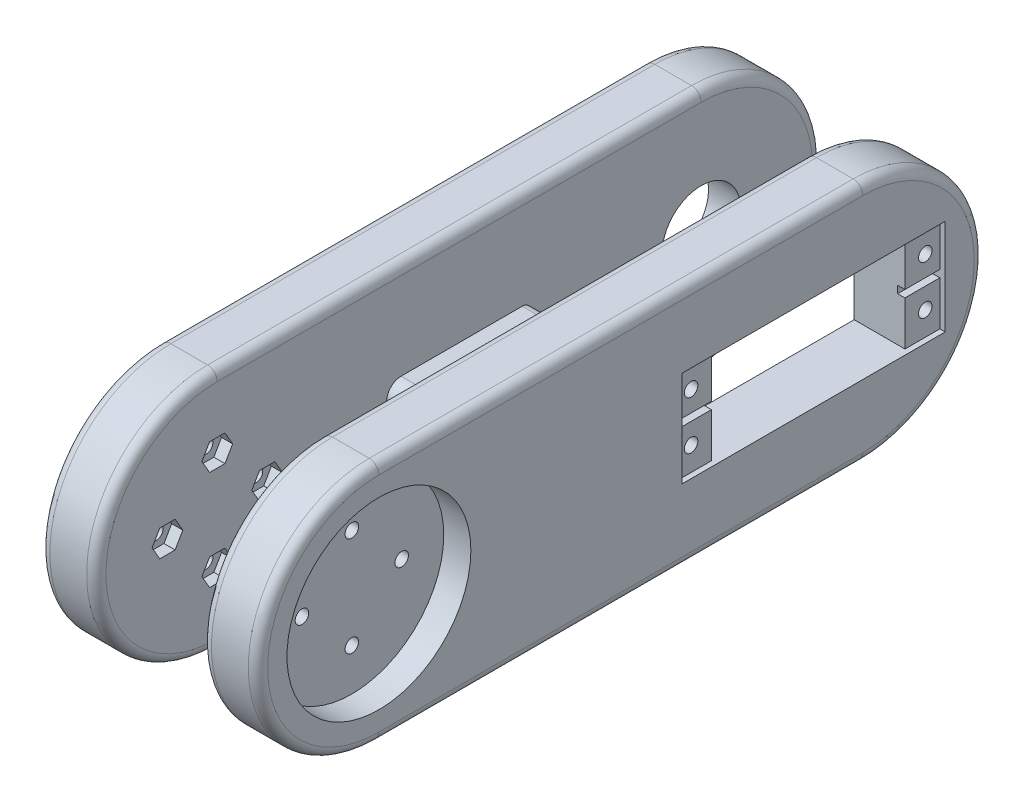
from build123d import *

# Parameters (mm, degrees)
SALIENTE_EXTRUIR1_DEPTH = 45
CROQUIS3_R              = 19
CORTAR_EXTRUIR1_DEPTH   = 5.6
CROQUIS4_R              = 19
CORTAR_EXTRUIR2_DEPTH   = 5.6
CROQUIS5_W              = 21.8
CROQUIS5_H              = 150
CORTAR_EXTRUIR3_DEPTH   = 55.6
CROQUIS6_W              = 30
CROQUIS6_H              = 10
SALIENTE_EXTRUIR2_DEPTH = 33.6
CROQUIS8_W              = 54.4
CROQUIS8_H              = 19.8
CORTAR_EXTRUIR4_DEPTH   = 1.1
CROQUIS9_W              = 40
CROQUIS9_H              = 19.8
CORTAR_EXTRUIR5_DEPTH   = 22
CROQUIS10_R             = 1.4
CORTAR_EXTRUIR6_DEPTH   = 9
CROQUIS11_W             = 54.4
CROQUIS11_H             = 1.5
CORTAR_EXTRUIR7_DEPTH   = 1.5
CROQUIS12_R             = 8.1
CORTAR_EXTRUIR8_DEPTH   = 17.5
CROQUIS13_R             = 17.5
CORTAR_EXTRUIR9_DEPTH   = 5
CROQUIS14_R             = 1.4
CORTAR_EXTRUIR10_DEPTH  = 5
CROQUIS15_R             = 1.4
CORTAR_EXTRUIR11_DEPTH  = 55
CORTAR_EXTRUIR12_DEPTH  = 2.3
CORTAR_EXTRUIR13_DEPTH  = 2.3
REDONDEO1_R             = 2
REDONDEO1_2_R           = 3


with BuildPart() as part:
    # Croquis2 → Saliente-Extruir1 (new body)
    with BuildSketch(Plane(origin=(0, 0, 0), x_dir=(0, 0, -1), z_dir=(1, 0, 0))):
        with BuildLine():
            Line((0, 25), (100, 25))
            ThreePointArc((100, 25), (125, -1.672e-06), (99.999996656, -25))
            Line((99.999996656, -25), (0, -25))
            ThreePointArc((0, -25), (-25, 0), (0, 25))
        make_face()
    extrude(amount=SALIENTE_EXTRUIR1_DEPTH)

    # Croquis3 → Cortar-Extruir1 (cut)
    with BuildSketch(Plane(origin=(45, 0, 0), x_dir=(0, 0, -1), z_dir=(1, 0, 0))):
        Circle(CROQUIS3_R)
    extrude(amount=-CORTAR_EXTRUIR1_DEPTH, mode=Mode.SUBTRACT)

    # Croquis4 → Cortar-Extruir2 (cut)
    with BuildSketch(Plane.ZY):
        with Locations(Location((0, 0, 0), (0, 0, 180))):  # turned: the seam where the file's is
            Circle(CROQUIS4_R)
    extrude(amount=-CORTAR_EXTRUIR2_DEPTH, mode=Mode.SUBTRACT)

    # Croquis5 → Cortar-Extruir3 (cut)
    with BuildSketch(Plane(origin=(0, 25, 0), x_dir=(1, 0, 0), z_dir=(0, 1, 0))):
        with Locations((22.5, 50)):
            Rectangle(CROQUIS5_W, CROQUIS5_H)
    extrude(amount=-CORTAR_EXTRUIR3_DEPTH, mode=Mode.SUBTRACT)

    # Croquis6 → Saliente-Extruir2 (add)
    with BuildSketch(Plane.ZY.offset(-5.6)):
        with Locations((-50, -1.672e-06)):
            Rectangle(CROQUIS6_W, CROQUIS6_H)
    extrude(amount=-SALIENTE_EXTRUIR2_DEPTH)

    # Croquis8 → Cortar-Extruir4 (cut)
    with BuildSketch(Plane(origin=(45, 0, 0), x_dir=(0, 0, -1), z_dir=(1, 0, 0))):
        with Locations((89.799996656, 0)):
            Rectangle(CROQUIS8_W, CROQUIS8_H)
    extrude(amount=-CORTAR_EXTRUIR4_DEPTH, mode=Mode.SUBTRACT)

    # Croquis9 → Cortar-Extruir5 (cut)
    with BuildSketch(Plane(origin=(43.9, 0, 0), x_dir=(0, 0, -1), z_dir=(1, 0, 0))):
        with Locations((89.799996656, 0)):
            Rectangle(CROQUIS9_W, CROQUIS9_H)
    extrude(amount=-CORTAR_EXTRUIR5_DEPTH, mode=Mode.SUBTRACT)

    # Croquis10 → Cortar-Extruir6 (cut)
    with BuildSketch(Plane(origin=(43.9, 0, 0), x_dir=(0, 0, -1), z_dir=(1, 0, 0))):
        with Locations((65.599996656, -5)):
            Circle(CROQUIS10_R)
        with Locations((65.599996656, 5)):
            Circle(CROQUIS10_R)
        with Locations((113.999996656, 5)):
            Circle(CROQUIS10_R)
        with Locations((113.999996656, -5)):
            Circle(CROQUIS10_R)
    extrude(amount=-CORTAR_EXTRUIR6_DEPTH, mode=Mode.SUBTRACT)

    # Croquis11 → Cortar-Extruir7 (cut)
    with BuildSketch(Plane(origin=(43.9, 0, 0), x_dir=(0, 0, -1), z_dir=(1, 0, 0))):
        with Locations((89.799996656, 0)):
            Rectangle(CROQUIS11_W, CROQUIS11_H)
    extrude(amount=-CORTAR_EXTRUIR7_DEPTH, mode=Mode.SUBTRACT)

    # Croquis12 → Cortar-Extruir8 (cut)
    with BuildSketch(Plane.ZY):
        with Locations((-100, 0)):
            Circle(CROQUIS12_R)
    extrude(amount=-CORTAR_EXTRUIR8_DEPTH, mode=Mode.SUBTRACT)

    # Croquis13 → Cortar-Extruir9 (cut)
    with BuildSketch(Plane.ZY):
        with Locations((-100, 0)):
            Circle(CROQUIS13_R)
    extrude(amount=-CORTAR_EXTRUIR9_DEPTH, mode=Mode.SUBTRACT)

    # Croquis14 → Cortar-Extruir10 (cut)
    with BuildSketch(Plane.ZY.offset(-5)):
        with Locations((-112.8, 0)):
            Circle(CROQUIS14_R)
        with Locations((-87.2, 0)):
            Circle(CROQUIS14_R)
    extrude(amount=-CORTAR_EXTRUIR10_DEPTH, mode=Mode.SUBTRACT)

    # Croquis15 → Cortar-Extruir11 (cut)
    with BuildSketch(Plane.ZY):
        with Locations(Location((-10.3, 0, 0), (0, 0, 180))):  # turned: the seam where the file's is
            Circle(CROQUIS15_R)
        with Locations(Location((10.3, 0, 0), (0, 0, 180))):  # turned: the seam where the file's is
            Circle(CROQUIS15_R)
        with Locations(Location((0, -10.3, 0), (0, 0, 180))):  # turned: the seam where the file's is
            Circle(CROQUIS15_R)
        with Locations(Location((0, 10.3, 0), (0, 0, 180))):  # turned: the seam where the file's is
            Circle(CROQUIS15_R)
    extrude(amount=-CORTAR_EXTRUIR11_DEPTH, mode=Mode.SUBTRACT)

    # Croquis16 → Cortar-Extruir12 (cut)
    with BuildSketch(Plane(origin=(11.6, 0, 0), x_dir=(0, 0, -1), z_dir=(1, 0, 0))):
        Polygon((-7.124573519, 0), (-8.71228676, 2.75), (-11.88771324, 2.75), (-13.475426481, 0), (-11.88771324, -2.75), (-8.71228676, -2.75), align=None)
        Polygon((13.475426481, 0), (11.88771324, 2.75), (8.71228676, 2.75), (7.124573519, 0), (8.71228676, -2.75), (11.88771324, -2.75), align=None)
        Polygon((3.175426481, 10.3), (1.58771324, 13.05), (-1.58771324, 13.05), (-3.175426481, 10.3), (-1.58771324, 7.55), (1.58771324, 7.55), align=None)
        Polygon((3.175426481, -10.3), (1.58771324, -7.55), (-1.58771324, -7.55), (-3.175426481, -10.3), (-1.58771324, -13.05), (1.58771324, -13.05), align=None)
    extrude(amount=-CORTAR_EXTRUIR12_DEPTH, mode=Mode.SUBTRACT)

    # Croquis17 → Cortar-Extruir13 (cut)
    with BuildSketch(Plane.ZY.offset(-33.4)):
        Polygon((3.175426481, 10.3), (1.58771324, 7.55), (-1.58771324, 7.55), (-3.175426481, 10.3), (-1.58771324, 13.05), (1.58771324, 13.05), align=None)
        Polygon((8.71228676, -2.75), (7.124573519, 0), (8.71228676, 2.75), (11.88771324, 2.75), (13.475426481, 0), (11.88771324, -2.75), align=None)
        Polygon((1.58771324, -7.55), (3.175426481, -10.3), (1.58771324, -13.05), (-1.58771324, -13.05), (-3.175426481, -10.3), (-1.58771324, -7.55), align=None)
        Polygon((-7.124573519, 0), (-8.71228676, -2.75), (-11.88771324, -2.75), (-13.475426481, 0), (-11.88771324, 2.75), (-8.71228676, 2.75), align=None)
    extrude(amount=-CORTAR_EXTRUIR13_DEPTH, mode=Mode.SUBTRACT)

    # Redondeo1
    redondeo1_edges = [part.edges().sort_by_distance(p)[0] for p in [
        (45, 25, -50),
        (0, 25, -50),
        (33.4, 25, -50),
        (11.6, 25, -50),
        (22.5, 4.999998328, -65),
        (22.5, -5.000001672, -65),
        (22.5, -5.000001672, -35),
    ]]
    fillet(redondeo1_edges, radius=REDONDEO1_R)

    # Redondeo1 2
    redondeo1_2_edges = [part.edges().sort_by_distance(p)[0] for p in [
        (22.5, 4.999998328, -35),
    ]]
    fillet(redondeo1_2_edges, radius=REDONDEO1_2_R)


solid = part.part
